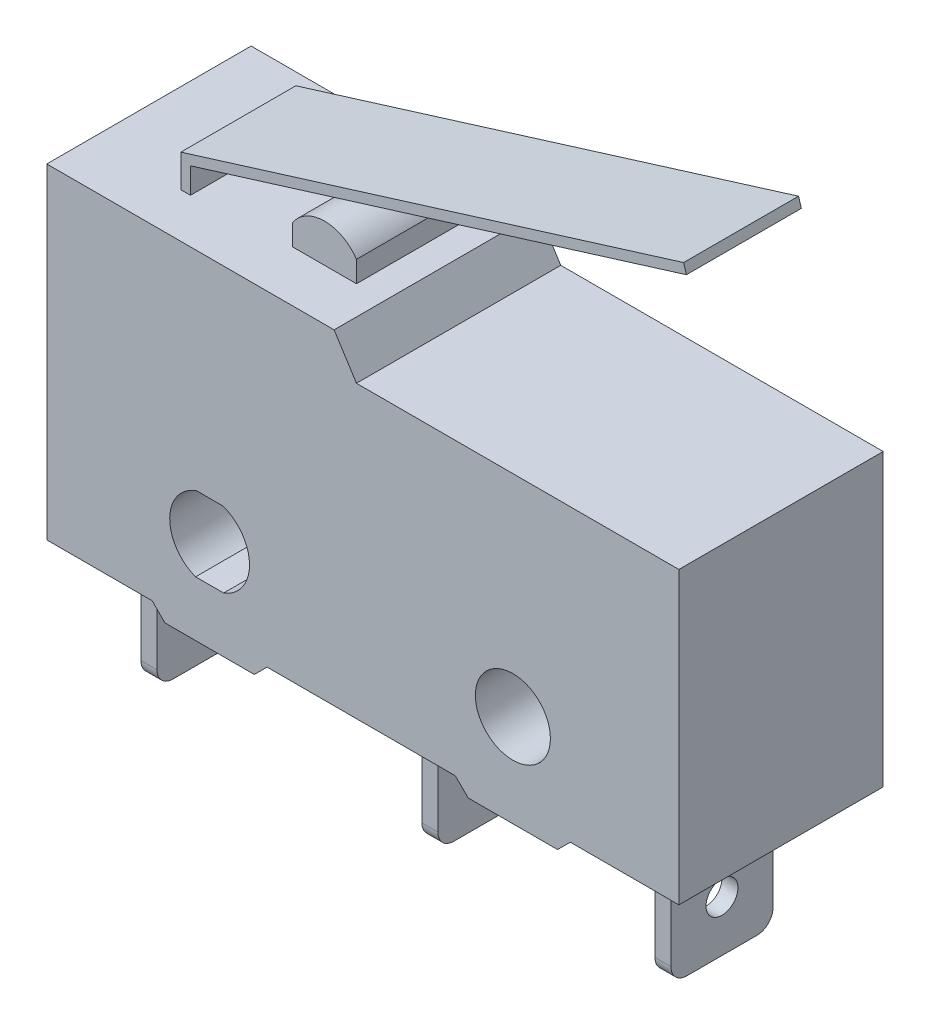
from build123d import *

# Parameters (mm, degrees)
BOSS_EXTRU_1_DEPTH                    = 3.6
ESQUISSE2_W                           = 19.8
ESQUISSE2_H                           = 10.6
BOSS_EXTRU_2_DEPTH                    = 1.4
ESQUISSE3_W                           = 19.8
ESQUISSE3_H                           = 10.6
BOSS_EXTRU_3_DEPTH                    = 1.4
ESQUISSE4_W                           = 3.6
ESQUISSE4_H                           = 0.3
BOSS_EXTRU_4_DEPTH                    = 16.265607889
ESQUISSE5_W                           = 10.8
ESQUISSE5_H                           = 1.1
ENL_V_MAT_EXTRU_1_DEPTH               = 7.4
ESQUISSE6_W                           = 3.8
ESQUISSE6_H                           = 0.4
ENL_V_MAT_EXTRU_2_DEPTH               = 7.4
ESQUISSE7_W                           = 6.7
ESQUISSE7_H                           = 0.4
ENL_V_MAT_EXTRU_3_DEPTH               = 7.4
ESQUISSE8_W                           = 3.7
ESQUISSE8_H                           = 0.4
ENL_V_MAT_EXTRU_4_DEPTH               = 7.4
ENL_V_MAT_EXTRU_5_DEPTH               = 7.4
BOSS_EXTRU_5_DEPTH                    = 3.2
ESQUISSE11_W                          = 0.5
ESQUISSE11_H                          = 3.2
BOSS_EXTRU_6_DEPTH                    = 3.9
ESQUISSE12_W                          = 0.5
ESQUISSE12_H                          = 3.2
BOSS_EXTRU_7_DEPTH                    = 3.9
ESQUISSE13_W                          = 0.5
ESQUISSE13_H                          = 3.2
BOSS_EXTRU_8_DEPTH                    = 3.9
D_POUILLE1_ANGLE                      = 32.471192291
D_POUILLE2_ANGLE                      = 45
D_POUILLE3_ANGLE                      = 45
DIAM_TRE_DU_PER_AGE_2_35_2_35_1_D     = 2.35
DIAM_TRE_DU_PER_AGE_2_35_2_35_1_DEPTH = 6.4
CONG_1_R                              = 0.5
ESQUISSE16_R                          = 0.5
ENL_V_MAT_EXTRU_6_DEPTH               = 19.45


with BuildPart() as part:
    # Esquisse1 → Boss.-Extru.1 (new body)
    with BuildSketch(Plane(origin=(0, 0, -1.8), x_dir=(-1, 0, 0), z_dir=(0, 0, -1))):
        Polygon((7.1, 11.621125946), (6.88877818, 11.686563143), (6.8, 11.4), (6.8, 10.6), (-9.9, 10.6), (-9.9, 0), (9.9, 0), (9.9, 10.6), (7.1, 10.6), align=None)
    extrude(amount=-BOSS_EXTRU_1_DEPTH)

    # Esquisse2 → Boss.-Extru.2 (add)
    with BuildSketch(Plane(origin=(0, 0, -1.8), x_dir=(-1, 0, 0), z_dir=(0, 0, -1))):
        with Locations((0, 5.3)):
            Rectangle(ESQUISSE2_W, ESQUISSE2_H)
    extrude(amount=BOSS_EXTRU_2_DEPTH)

    # Esquisse3 → Boss.-Extru.3 (add)
    with BuildSketch(Plane.XY.offset(1.8)):
        with Locations((0, 5.3)):
            Rectangle(ESQUISSE3_W, ESQUISSE3_H)
    extrude(amount=BOSS_EXTRU_3_DEPTH)

    # Esquisse4 → Boss.-Extru.4 (add)
    with BuildSketch(Plane(origin=(-2.982033775, -0.923843615, 0), x_dir=(0, 0, -1), z_dir=(0.955210476, 0.295927265, 0))):
        with Locations((0, 13.051704831)):
            Rectangle(ESQUISSE4_W, ESQUISSE4_H)
    extrude(amount=BOSS_EXTRU_4_DEPTH)

    # Esquisse5 → Enlèv. mat.-Extru.1 (cut, through all)
    with BuildSketch(Plane.XY.offset(3.2)):
        with Locations((4.5, 10.05)):
            Rectangle(ESQUISSE5_W, ESQUISSE5_H)
    extrude(amount=-ENL_V_MAT_EXTRU_1_DEPTH, mode=Mode.SUBTRACT)

    # Esquisse6 → Enlèv. mat.-Extru.2 (cut, through all)
    with BuildSketch(Plane.XY.offset(3.2)):
        with Locations((8, 0.2)):
            Rectangle(ESQUISSE6_W, ESQUISSE6_H)
    extrude(amount=-ENL_V_MAT_EXTRU_2_DEPTH, mode=Mode.SUBTRACT)

    # Esquisse7 → Enlèv. mat.-Extru.3 (cut, through all)
    with BuildSketch(Plane.XY.offset(3.2)):
        with Locations((-0.05, 0.2)):
            Rectangle(ESQUISSE7_W, ESQUISSE7_H)
    extrude(amount=-ENL_V_MAT_EXTRU_3_DEPTH, mode=Mode.SUBTRACT)

    # Esquisse8 → Enlèv. mat.-Extru.4 (cut, through all)
    with BuildSketch(Plane.XY.offset(3.2)):
        with Locations((-8.05, 0.2)):
            Rectangle(ESQUISSE8_W, ESQUISSE8_H)
    extrude(amount=-ENL_V_MAT_EXTRU_4_DEPTH, mode=Mode.SUBTRACT)

    # Esquisse9 → Enlèv. mat.-Extru.5 (cut, through all)
    with BuildSketch(Plane.XY.offset(3.2)):
        with BuildLine():
            Line((-5.24, 1.73), (-4.36, 1.73))
            ThreePointArc((-4.36, 1.73), (-3.550086003, 2.914662921), (-4.387568187, 4.08))
            Line((-4.387568187, 4.08), (-5.212431813, 4.08))
            ThreePointArc((-5.212431813, 4.08), (-6.049913997, 2.914662921), (-5.24, 1.73))
        make_face()
    extrude(amount=-ENL_V_MAT_EXTRU_5_DEPTH, mode=Mode.SUBTRACT)

    # Esquisse10 → Boss.-Extru.5 (add)
    with BuildSketch(Plane(origin=(0, 0, -1.6), x_dir=(-1, 0, 0), z_dir=(0, 0, -1))):
        with BuildLine():
            Line((1.8, 10.6), (3.8, 10.6))
            Line((3.8, 10.6), (3.8, 11.263324958))
            ThreePointArc((3.8, 11.263324958), (2.8, 11.8), (1.8, 11.263324958))
            Line((1.8, 11.263324958), (1.8, 10.6))
        make_face()
    extrude(amount=-BOSS_EXTRU_5_DEPTH)

    # Esquisse11 → Boss.-Extru.6 (add)
    with BuildSketch(Plane.XZ.offset(-0.4)):
        with Locations((-8.3, 0)):
            Rectangle(ESQUISSE11_W, ESQUISSE11_H)
    extrude(amount=BOSS_EXTRU_6_DEPTH)

    # Esquisse12 → Boss.-Extru.7 (add)
    with BuildSketch(Plane.XZ.offset(-0.4)):
        with Locations((0.5, 0)):
            Rectangle(ESQUISSE12_W, ESQUISSE12_H)
    extrude(amount=BOSS_EXTRU_7_DEPTH)

    # Esquisse13 → Boss.-Extru.8 (add)
    with BuildSketch(Plane.XZ.offset(-0.4)):
        with Locations((7.8, 0)):
            Rectangle(ESQUISSE13_W, ESQUISSE13_H)
    extrude(amount=BOSS_EXTRU_8_DEPTH)

    # Dépouille1
    d_pouille1_faces = [part.faces().sort_by_distance(p)[0] for p in [
        (-0.9, 10.05, 0),
    ]]
    draft(d_pouille1_faces, Plane(origin=(-9.9, 10.6, 1.8), x_dir=(0, 0, 1), z_dir=(0, 1, 0)), D_POUILLE1_ANGLE)

    # Dépouille2
    d_pouille2_faces = [part.faces().sort_by_distance(p)[0] for p in [
        (6.1, 0.2, 0),
        (3.3, 0.2, 0),
    ]]
    draft(d_pouille2_faces, Plane(origin=(9.9, 0, 1.8), x_dir=(0, 0, -1), z_dir=(0, -1, 0)), D_POUILLE2_ANGLE)

    # Dépouille3
    d_pouille3_faces = [part.faces().sort_by_distance(p)[0] for p in [
        (-3.4, 0.2, 0),
        (-6.2, 0.2, 0),
    ]]
    draft(d_pouille3_faces, Plane(origin=(9.9, 0, 1.8), x_dir=(0, 0, -1), z_dir=(0, -1, 0)), D_POUILLE3_ANGLE)

    # Diamètre du perçage Ø2.35 (2.35)1
    with Locations(Plane.XY.offset(3.2)):
        with Locations((4.7, 2.9)):
            Hole(DIAM_TRE_DU_PER_AGE_2_35_2_35_1_D / 2, depth=DIAM_TRE_DU_PER_AGE_2_35_2_35_1_DEPTH)

    # Congé1
    cong_1_edges = [part.edges().sort_by_distance(p)[0] for p in [
        (-8.3, -3.5, -1.6),
        (-8.3, -3.5, 1.6),
        (0.5, -3.5, -1.6),
        (0.5, -3.5, 1.6),
        (7.8, -3.5, -1.6),
        (7.8, -3.5, 1.6),
    ]]
    fillet(cong_1_edges, radius=CONG_1_R)

    # Esquisse16 → Enlèv. mat.-Extru.6 (cut, through all)
    with BuildSketch(Plane.ZY.offset(8.55)):
        with Locations((0, -1.907139158)):
            Circle(ESQUISSE16_R)
    extrude(amount=-ENL_V_MAT_EXTRU_6_DEPTH, mode=Mode.SUBTRACT)


solid = part.part
